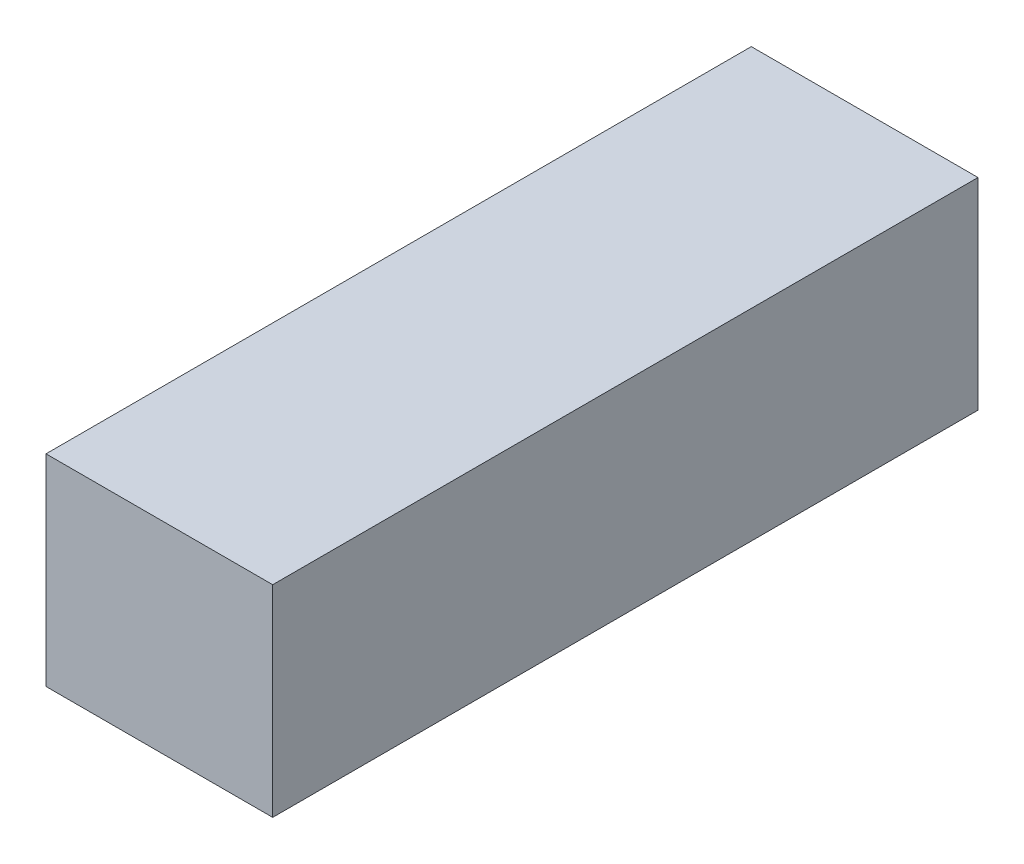
from build123d import *

# Parameters (mm, degrees)
SKETCH1_W           = 4.5
SKETCH1_H           = 4
BOSS_EXTRUDE1_DEPTH = 7


with BuildPart() as part:
    # Sketch1 → Boss-Extrude1 (new body, symmetric)
    with BuildSketch(Plane.XY):
        Rectangle(SKETCH1_W, SKETCH1_H)
    extrude(amount=BOSS_EXTRUDE1_DEPTH, both=True)


solid = part.part
